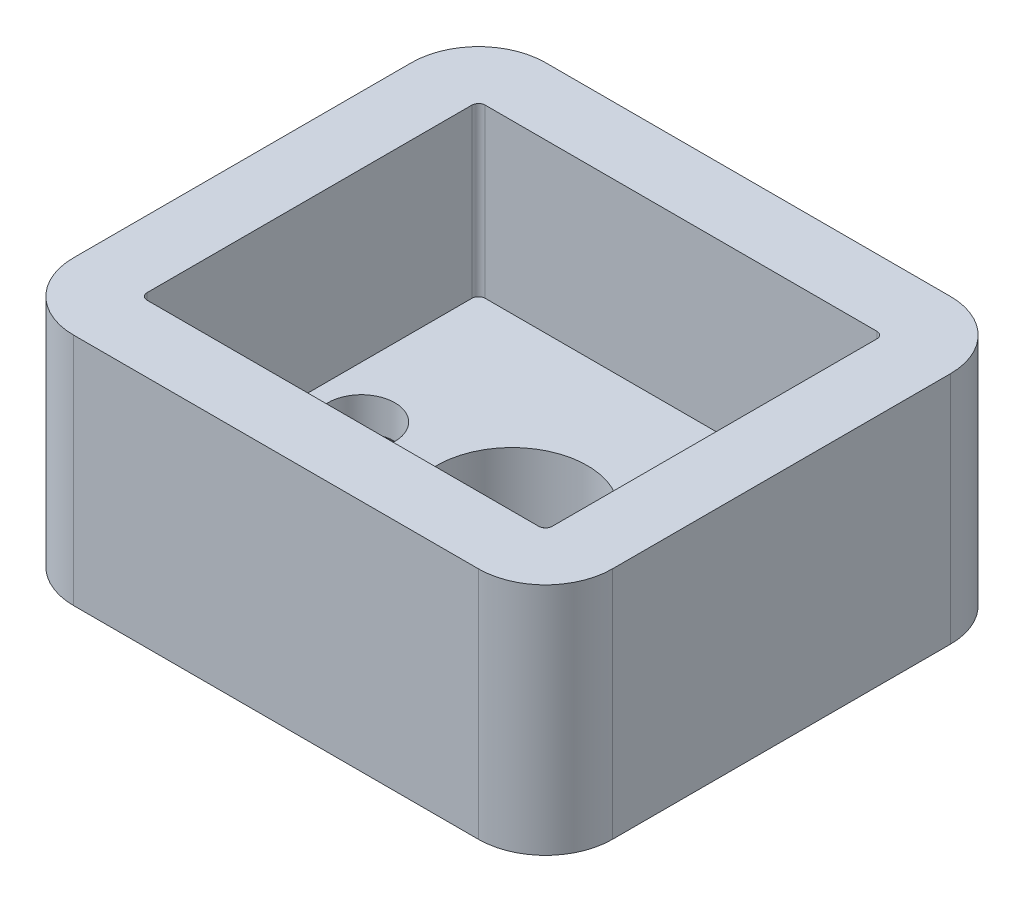
from build123d import *

# Parameters (mm, degrees)
SKETCH1_W                                            = 16.1
SKETCH1_H                                            = 14.1
BOSS_EXTRUDE1_DEPTH                                  = 7
SKETCH3_W                                            = 12.1
SKETCH3_H                                            = 10.1
CUT_EXTRUDE1_DEPTH                                   = 5
CSK_FOR_M1_6_COUNTERSUNK_FLAT_HEAD_SCREW_D           = 2
CSK_FOR_M1_6_COUNTERSUNK_FLAT_HEAD_SCREW_DEPTH       = 2
CSK_FOR_M1_6_COUNTERSUNK_FLAT_HEAD_SCREW_CSINK_D     = 4
CSK_FOR_M1_6_COUNTERSUNK_FLAT_HEAD_SCREW_CSINK_ANGLE = 90
SKETCH8_R                                            = 2.25
CUT_EXTRUDE2_DEPTH                                   = 3
FILLET1_R                                            = 2
FILLET2_R                                            = 0.2


with BuildPart() as part:
    # Sketch1 → Boss-Extrude1 (new body)
    with BuildSketch(Plane(origin=(0, 0, 0), x_dir=(1, 0, 0), z_dir=(0, 1, 0))):
        Rectangle(SKETCH1_W, SKETCH1_H)
    extrude(amount=BOSS_EXTRUDE1_DEPTH)

    # Sketch3 → Cut-Extrude1 (cut)
    with BuildSketch(Plane(origin=(0, 7, 0), x_dir=(1, 0, 0), z_dir=(0, 1, 0))):
        Rectangle(SKETCH3_W, SKETCH3_H)
    extrude(amount=-CUT_EXTRUDE1_DEPTH, mode=Mode.SUBTRACT)

    # CSK for M1.6 Countersunk Flat Head Screw1
    with Locations(Plane(origin=(0, 0, 0), x_dir=(-1, 0, 0), z_dir=(0, -1, 0))):
        with Locations((4.5, 0), (-4.5, 0)):
            CounterSinkHole(CSK_FOR_M1_6_COUNTERSUNK_FLAT_HEAD_SCREW_D / 2, CSK_FOR_M1_6_COUNTERSUNK_FLAT_HEAD_SCREW_CSINK_D / 2, depth=CSK_FOR_M1_6_COUNTERSUNK_FLAT_HEAD_SCREW_DEPTH, counter_sink_angle=CSK_FOR_M1_6_COUNTERSUNK_FLAT_HEAD_SCREW_CSINK_ANGLE)

    # Sketch8 → Cut-Extrude2 (cut, through all)
    with BuildSketch(Plane(origin=(0, 2, 0), x_dir=(1, 0, 0), z_dir=(0, 1, 0))):
        Circle(SKETCH8_R)
    extrude(amount=-CUT_EXTRUDE2_DEPTH, mode=Mode.SUBTRACT)

    # Fillet1
    fillet1_edges = [part.edges().sort_by_distance(p)[0] for p in [
        (-8.05, 3.5, -7.05),
        (8.05, 3.5, -7.05),
        (8.05, 3.5, 7.05),
        (-8.05, 3.5, 7.05),
    ]]
    fillet(fillet1_edges, radius=FILLET1_R)

    # Fillet2
    fillet2_edges = [part.edges().sort_by_distance(p)[0] for p in [
        (-6.05, 4.5, 5.05),
        (-6.05, 4.5, -5.05),
        (6.05, 4.5, -5.05),
        (6.05, 4.5, 5.05),
    ]]
    fillet(fillet2_edges, radius=FILLET2_R)


solid = part.part
